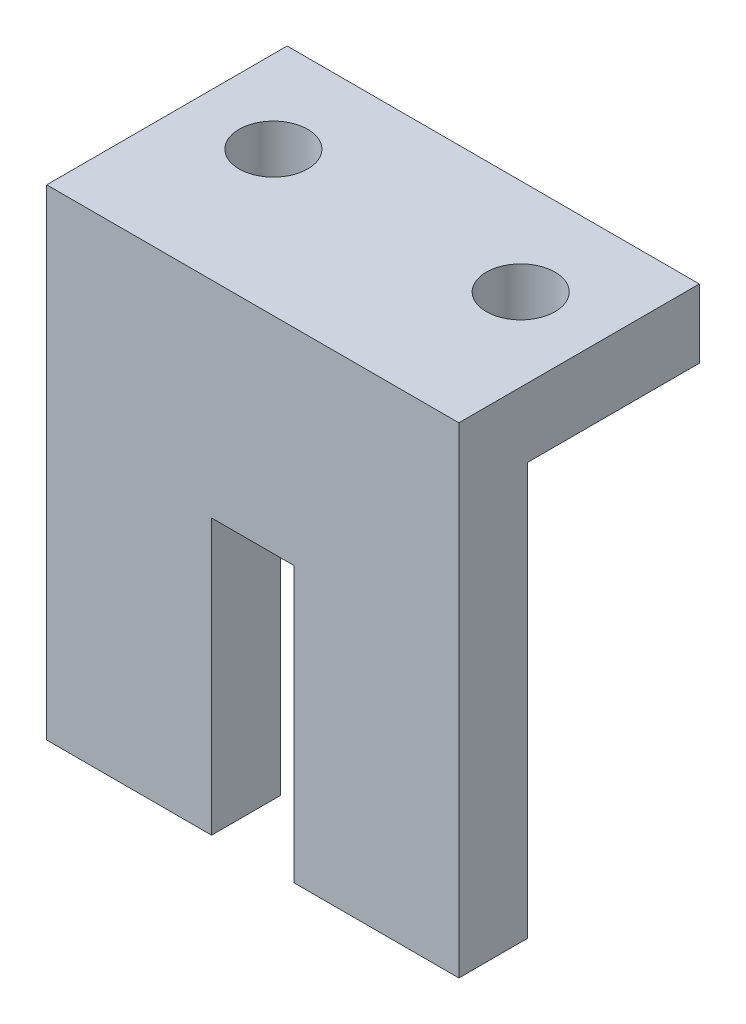
from build123d import *

# Parameters (mm, degrees)
BOSS_EXTRUDE1_DEPTH = 5
SKETCH2_W           = 30
SKETCH2_H           = 5
BOSS_EXTRUDE2_DEPTH = 19
SKETCH3_R           = 2.5
CUT_EXTRUDE1_DEPTH  = 19
SKETCH4_W           = 30
SKETCH4_H           = 6.5
CUT_EXTRUDE2_DEPTH  = 36


with BuildPart() as part:
    # Sketch1 → Boss-Extrude1 (new body)
    with BuildSketch(Plane.XY):
        Polygon((12, 0), (12, 20), (18, 20), (18, 0), (30, 0), (30, 30), (30, 35), (0, 35), (0, 30), (0, 0), align=None)
    extrude(amount=BOSS_EXTRUDE1_DEPTH)

    # Sketch2 → Boss-Extrude2 (add)
    with BuildSketch(Plane(origin=(0, 0, 0), x_dir=(-1, 0, 0), z_dir=(0, 0, -1))):
        with Locations((-15, 32.5)):
            Rectangle(SKETCH2_W, SKETCH2_H)
    extrude(amount=BOSS_EXTRUDE2_DEPTH)

    # Sketch3 → Cut-Extrude1 (cut)
    with BuildSketch(Plane(origin=(0, 35, 0), x_dir=(1, 0, 0), z_dir=(0, 1, 0))):
        with Locations((6, 5.5)):
            Circle(SKETCH3_R)
        with Locations((24, 5.5)):
            Circle(SKETCH3_R)
    extrude(amount=-CUT_EXTRUDE1_DEPTH, mode=Mode.SUBTRACT)

    # Sketch4 → Cut-Extrude2 (cut, through all)
    with BuildSketch(Plane(origin=(0, 35, 0), x_dir=(1, 0, 0), z_dir=(0, 1, 0))):
        with Locations((15, 15.75)):
            Rectangle(SKETCH4_W, SKETCH4_H)
    extrude(amount=-CUT_EXTRUDE2_DEPTH, mode=Mode.SUBTRACT)


solid = part.part
